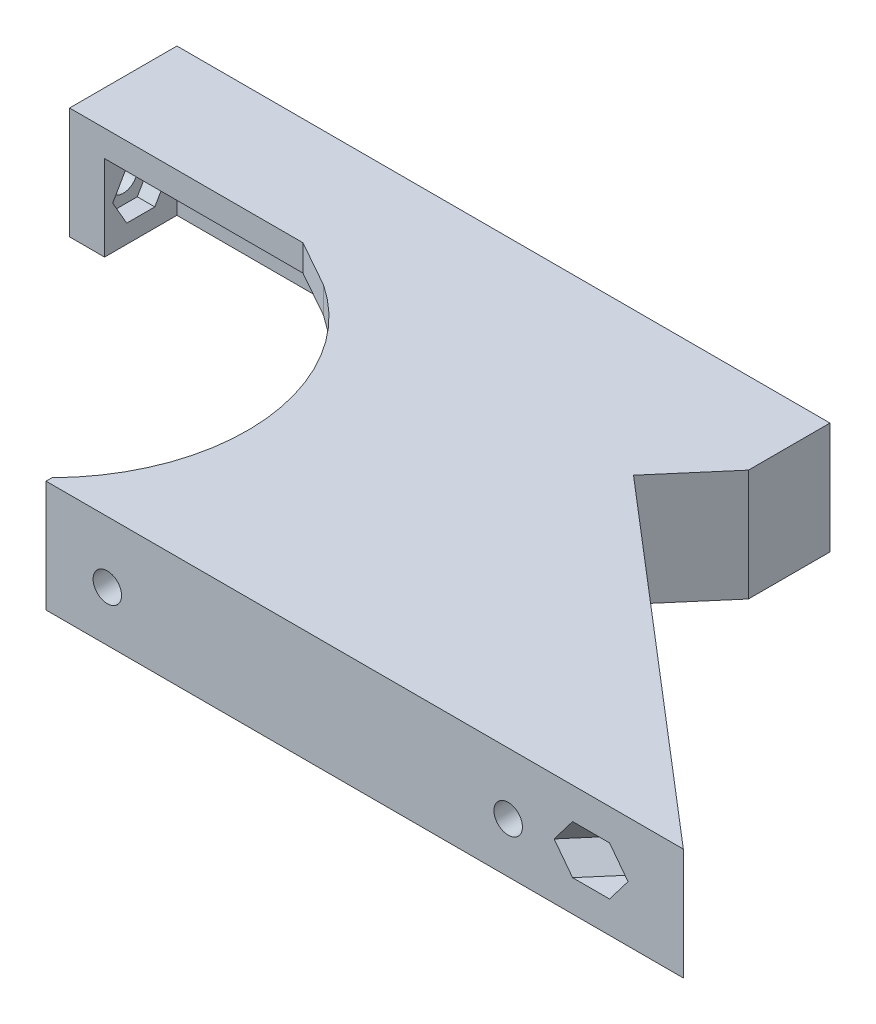
from build123d import *

# Parameters (mm, degrees)
SALIENTE_EXTRUIR1_DEPTH     = 12.75
CORTAR_EXTRUIR1_REACH       = 31.62
CROQUIS2_R                  = 1.625
CROQUIS3_R                  = 22.5
CORTAR_EXTRUIR2_DEPTH       = 13.75
SALIENTE_EXTRUIR2_DEPTH     = 3
SALIENTE_EXTRUIR3_DEPTH     = 9.75
CROQUIS6_R                  = 1.625
CORTAR_EXTRUIR3_DEPTH       = 10
CORTAR_EXTRUIR4_START       = -2
CORTAR_EXTRUIR4_DEPTH       = 10
CORTAR_EXTRUIR5_START       = -2
CORTAR_EXTRUIR5_DEPTH       = 10
CORTAR_EXTRUIR6_DEPTH       = 2
CORTAR_EXTRUIR7_REACH       = 37.25
CROQUIS10_R                 = 1.625
CORTAR_EXTRUIR8_DEPTH       = 2
CROQUIS12_W                 = 92.508691999
CROQUIS12_H                 = 24.255818813
CORTAR_EXTRUIR9_DEPTH       = 1
CORTAR_EXTRUIR9_DEPTH_BACK  = 36.25
SALIENTE_EXTRUIR4_DEPTH     = 12.75
CORTAR_EXTRUIR10_START      = -9.75
CORTAR_EXTRUIR10_DEPTH      = 9.75
CROQUIS16_W                 = 68.039065087
CROQUIS16_H                 = 12.75
CORTAR_EXTRUIR11_DEPTH      = 1
CROQUIS17_W                 = 40.657498706
CROQUIS17_H                 = 22.934549925
CORTAR_EXTRUIR12_DEPTH      = 1
CORTAR_EXTRUIR12_DEPTH_BACK = 13.75
SALIENTE_EXTRUIR5_REACH     = 14.75
CROQUIS18_W                 = 34.9120451
CROQUIS18_H                 = 3.951156815
CROQUIS20_R                 = 1.625
CORTAR_EXTRUIR14_DEPTH      = 10
CORTAR_EXTRUIR15_DEPTH      = 2
CROQUIS22_R                 = 1.625
CORTAR_EXTRUIR16_DEPTH      = 10
CORTAR_EXTRUIR17_DEPTH      = 2
SALIENTE_EXTRUIR6_DEPTH     = 12.75
CORTAR_EXTRUIR18_DEPTH      = 2
CROQUIS28_R                 = 1.625
SALIENTE_EXTRUIR7_DEPTH     = 1
CORTAR_EXTRUIR19_REACH      = 110.346
CROQUIS29_R                 = 1.625
CORTAR_EXTRUIR20_DEPTH      = 2
SALIENTE_EXTRUIR11_DEPTH    = 12.75
CROQUIS41_R                 = 1.625
CORTAR_EXTRUIR25_DEPTH      = 10
SALIENTE_EXTRUIR12_DEPTH    = 12.75
SALIENTE_EXTRUIR13_DEPTH    = 12.75
CORTAR_EXTRUIR26_DEPTH      = 13.75
SALIENTE_EXTRUIR14_START    = -9.15
SALIENTE_EXTRUIR14_DEPTH    = 5.55
SALIENTE_EXTRUIR15_REACH    = 14.75
CORTAR_EXTRUIR27_REACH      = 110.346
CROQUIS47_R                 = 1.625
CORTAR_EXTRUIR28_REACH      = 112.346
CORTAR_EXTRUIR28_START      = -2
CORTAR_EXTRUIR29_START      = -9.75
CORTAR_EXTRUIR29_DEPTH      = 9.75
CORTAR_EXTRUIR30_REACH      = 52.512
CROQUIS50_R                 = 1.625
CORTAR_EXTRUIR31_REACH      = 54.512
CORTAR_EXTRUIR31_START      = -2
CROQUIS19_W                 = 120.448667976
CROQUIS19_H                 = 32.886651308
CORTAR_EXTRUIR13_DEPTH      = 1
CORTAR_EXTRUIR13_DEPTH_BACK = 62.623336743


with BuildPart() as part:
    # Croquis1 → Saliente-Extruir1 (new body)
    with BuildSketch(Plane(origin=(0, 0, 0), x_dir=(1, 0, 0), z_dir=(0, 1, 0))):
        Polygon((0, 0), (72.78319995, 0), (38.224450787, 29.62043043), (35.621353918, 26.5833452), (60.803074847, 5), (0, 5), align=None)
    extrude(amount=SALIENTE_EXTRUIR1_DEPTH)

    # Croquis2 → Cortar-Extruir1 (cut, up to next)
    with BuildSketch(Plane.XY, mode=Mode.PRIVATE) as cortar_extruir1_sk1:
        with Locations((52.78319995, 5.75)):
            Circle(CROQUIS2_R)
    cortar_extruir1_tool1 = extrude(cortar_extruir1_sk1.sketch, amount=-CORTAR_EXTRUIR1_REACH, mode=Mode.PRIVATE) & part.part
    add(cortar_extruir1_tool1.solids().sort_by_distance((52.7832, 5.75, 0))[0], mode=Mode.SUBTRACT)
    # Croquis2 → Cortar-Extruir1 (cut, up to next)
    with BuildSketch(Plane.XY, mode=Mode.PRIVATE) as cortar_extruir1_sk2:
        with Locations((6.99999995, 5.75)):
            Circle(CROQUIS2_R)
    cortar_extruir1_tool2 = extrude(cortar_extruir1_sk2.sketch, amount=-CORTAR_EXTRUIR1_REACH, mode=Mode.PRIVATE) & part.part
    add(cortar_extruir1_tool2.solids().sort_by_distance((7, 5.75, 0))[0], mode=Mode.SUBTRACT)

    # Croquis3 → Cortar-Extruir2 (cut, through all)
    with BuildSketch(Plane(origin=(0, 12.75, 0), x_dir=(1, 0, 0), z_dir=(0, 1, 0))):
        with Locations((-16, 16.5)):
            Circle(CROQUIS3_R)
    extrude(amount=-CORTAR_EXTRUIR2_DEPTH, mode=Mode.SUBTRACT)

    # Croquis4 → Saliente-Extruir2 (add)
    with BuildSketch(Plane(origin=(0, 12.75, 0), x_dir=(1, 0, 0), z_dir=(0, 1, 0))):
        with BuildLine():
            Line((38.224450787, 29.62043043), (31.656319269, 35.25))
            Line((31.656319269, 35.25), (-3.562657036, 35.25))
            ThreePointArc((-3.562657036, 35.25), (5.936291456, 21.504909307), (3.339079606, 5))
            Line((3.339079606, 5), (60.803074847, 5))
            Line((60.803074847, 5), (35.621353918, 26.5833452))
            Line((35.621353918, 26.5833452), (38.224450787, 29.62043043))
        make_face()
    extrude(amount=-SALIENTE_EXTRUIR2_DEPTH)

    # Croquis5 → Saliente-Extruir3 (add)
    with BuildSketch(Plane.XZ.offset(-9.75)):
        with BuildLine():
            Line((-3.562657036, -35.25), (31.656319269, -35.25))
            Line((31.656319269, -35.25), (38.224450787, -29.62043043))
            Line((38.224450787, -29.62043043), (35.621353918, -26.5833452))
            Line((35.621353918, -26.5833452), (30.17667434, -31.25))
            Line((30.17667434, -31.25), (0.990806338, -31.25))
            ThreePointArc((0.990806338, -31.25), (-1.15062315, -33.404023402), (-3.562657036, -35.25))
        make_face()
    extrude(amount=SALIENTE_EXTRUIR3_DEPTH)

    # Croquis6 → Cortar-Extruir3 (cut)
    with BuildSketch(Plane(origin=(30.824200619, 0, -35.963211942), x_dir=(-0.759271307, 0, -0.650774217), z_dir=(0.650774217, 0, -0.759271307))):
        with Locations((-47.262195378, 6.375)):
            Circle(CROQUIS6_R)
        with Locations((-7.442195378, 6.375)):
            Circle(CROQUIS6_R)
    extrude(amount=-CORTAR_EXTRUIR3_DEPTH, mode=Mode.SUBTRACT)

    # Croquis7 → Cortar-Extruir4 (cut)
    with BuildSketch(Plane(origin=(28.22110375, 0, -32.926126712), x_dir=(0.759271307, 0, 0.650774217), z_dir=(-0.650774217, 0, 0.759271307)).offset(CORTAR_EXTRUIR4_START)):
        Polygon((48.864342375, 3.6), (50.466489372, 6.375), (48.864342375, 9.15), (45.660048381, 9.15), (44.057901384, 6.375), (45.660048381, 3.6), align=None)
    extrude(amount=CORTAR_EXTRUIR4_DEPTH, mode=Mode.SUBTRACT)

    # Croquis8 → Cortar-Extruir5 (cut)
    with BuildSketch(Plane(origin=(28.22110375, 0, -32.926126712), x_dir=(0.759271307, 0, 0.650774217), z_dir=(-0.650774217, 0, 0.759271307)).offset(CORTAR_EXTRUIR5_START)):
        Polygon((9.044342375, 3.6), (10.646489372, 6.375), (9.044342375, 9.15), (5.840048381, 9.15), (4.237901384, 6.375), (5.840048381, 3.6), align=None)
    extrude(amount=CORTAR_EXTRUIR5_DEPTH, mode=Mode.SUBTRACT)

    # Croquis9 → Cortar-Extruir6 (cut)
    with BuildSketch(Plane(origin=(0, 0, -5), x_dir=(-1, 0, 0), z_dir=(0, 0, -1))):
        Polygon((-5.397852953, 2.975), (-3.795705956, 5.75), (-5.397852953, 8.525), (-8.602146947, 8.525), (-10.204293944, 5.75), (-8.602146947, 2.975), align=None)
        Polygon((-51.181052953, 2.975), (-49.578905956, 5.75), (-51.181052953, 8.525), (-54.385346947, 8.525), (-55.987493944, 5.75), (-54.385346947, 2.975), align=None)
    extrude(amount=-CORTAR_EXTRUIR6_DEPTH, mode=Mode.SUBTRACT)

    # Croquis10 → Cortar-Extruir7 (cut, up to next)
    with BuildSketch(Plane(origin=(0, 0, -35.25), x_dir=(-1, 0, 0), z_dir=(0, 0, -1)), mode=Mode.PRIVATE) as cortar_extruir7_sk1:
        with Locations((-21.656319269, 6.375)):
            Circle(CROQUIS10_R)
    cortar_extruir7_tool1 = extrude(cortar_extruir7_sk1.sketch, amount=-CORTAR_EXTRUIR7_REACH, mode=Mode.PRIVATE) & part.part
    add(cortar_extruir7_tool1.solids().sort_by_distance((21.656319, 6.375, -35.25))[0], mode=Mode.SUBTRACT)

    # Croquis11 → Cortar-Extruir8 (cut)
    with BuildSketch(Plane.XY.offset(-31.25)):
        Polygon((23.258466266, 3.6), (24.860613263, 6.375), (23.258466266, 9.15), (20.054172272, 9.15), (18.452025275, 6.375), (20.054172272, 3.6), align=None)
    extrude(amount=-CORTAR_EXTRUIR8_DEPTH, mode=Mode.SUBTRACT)

    # Simetría1: part across plane


with BuildPart() as part_1:
    add(part.part)
    add(part.part.mirror(Plane.ZX))

    # Croquis12 → Cortar-Extruir9 (cut, two sides)
    with BuildSketch(Plane(origin=(0, 0, -35.25), x_dir=(-1, 0, 0), z_dir=(0, 0, -1))) as cortar_extruir9_sk:
        with Locations((-33.077560565, 12.127909407)):
            Rectangle(CROQUIS12_W, CROQUIS12_H)
    extrude(amount=CORTAR_EXTRUIR9_DEPTH, mode=Mode.SUBTRACT)
    extrude(cortar_extruir9_sk.sketch, amount=-CORTAR_EXTRUIR9_DEPTH_BACK, mode=Mode.SUBTRACT)

    # Croquis13 → Saliente-Extruir4 (add)
    with BuildSketch(Plane.XZ.offset(12.75)):
        Polygon((-35.562657036, -82.38260805), (-35.562657036, -38.25), (-8.913300435, -38.25), (-3.562657036, -35.25), (31.656319269, -35.25), (0.000162281, -62.38260805), align=None)
    extrude(amount=-SALIENTE_EXTRUIR4_DEPTH)

    # Croquis14 → Cortar-Extruir10 (cut)
    with BuildSketch(Plane(origin=(0, 0, 0), x_dir=(1, 0, 0), z_dir=(0, 1, 0)).offset(CORTAR_EXTRUIR10_START)):
        Polygon((30.17667434, 31.25), (0.990806338, 31.25), (-31.562657036, 38.25), (-31.562657036, 75.543902968), (-2.303881466, 59.089203295), align=None)
    extrude(amount=CORTAR_EXTRUIR10_DEPTH, mode=Mode.SUBTRACT)

    # Croquis16 → Cortar-Extruir11 (cut)
    with BuildSketch(Plane(origin=(30.824200619, 0, -35.963211942), x_dir=(-0.759271307, 0, -0.650774217), z_dir=(0.650774217, 0, -0.759271307))):
        with Locations((6.577337166, -6.375)):
            Rectangle(CROQUIS16_W, CROQUIS16_H)
    extrude(amount=-CORTAR_EXTRUIR11_DEPTH, mode=Mode.SUBTRACT)

    # Croquis17 → Cortar-Extruir12 (cut, two sides)
    with BuildSketch(Plane.XZ.offset(12.75)) as cortar_extruir12_sk:
        with Locations((-20.328587072, -73.090611706)):
            Rectangle(CROQUIS17_W, CROQUIS17_H)
    extrude(amount=CORTAR_EXTRUIR12_DEPTH, mode=Mode.SUBTRACT)
    extrude(cortar_extruir12_sk.sketch, amount=-CORTAR_EXTRUIR12_DEPTH_BACK, mode=Mode.SUBTRACT)

    # Croquis18 → Saliente-Extruir5 (add, up to next)
    with BuildSketch(Plane(origin=(0, 0, 0), x_dir=(1, 0, 0), z_dir=(0, 1, 0)), mode=Mode.PRIVATE) as saliente_extruir5_sk1:
        with Locations((-18.106634486, 59.647758336)):
            Rectangle(CROQUIS18_W, CROQUIS18_H)
    saliente_extruir5_tool1 = extrude(saliente_extruir5_sk1.sketch, amount=-SALIENTE_EXTRUIR5_REACH, mode=Mode.PRIVATE) - part_1.part
    add(saliente_extruir5_tool1.solids().sort_by_distance((-18.106634, 0, -59.647758))[0])

    # Croquis20 → Cortar-Extruir14 (cut)
    with BuildSketch(Plane(origin=(30.173426402, 0, -35.203940634), x_dir=(-0.759271307, 0, -0.650774217), z_dir=(0.650774217, 0, -0.759271307))):
        with Locations((25.596869709, -6.375)):
            Circle(CROQUIS20_R)
        with Locations((-7.442195378, -6.375)):
            Circle(CROQUIS20_R)
    extrude(amount=-CORTAR_EXTRUIR14_DEPTH, mode=Mode.SUBTRACT)

    # Croquis21 → Cortar-Extruir15 (cut)
    with BuildSketch(Plane(origin=(28.22110375, 0, -32.926126712), x_dir=(0.759271307, 0, 0.650774217), z_dir=(-0.650774217, 0, 0.759271307))):
        Polygon((-23.994722712, -9.15), (-22.392575715, -6.375), (-23.994722712, -3.6), (-27.199016706, -3.6), (-28.801163703, -6.375), (-27.199016706, -9.15), align=None)
    extrude(amount=-CORTAR_EXTRUIR15_DEPTH, mode=Mode.SUBTRACT)

    # Croquis22 → Cortar-Extruir16 (cut)
    with BuildSketch(Plane(origin=(0, 0, -61.623336743), x_dir=(-1, 0, 0), z_dir=(0, 0, -1))):
        with Locations((18.112657036, -6.375)):
            Circle(CROQUIS22_R)
    extrude(amount=-CORTAR_EXTRUIR16_DEPTH, mode=Mode.SUBTRACT)

    # Croquis23 → Cortar-Extruir17 (cut)
    with BuildSketch(Plane.XY.offset(-57.672179928)):
        Polygon((-16.510510039, -9.15), (-14.908363042, -6.375), (-16.510510039, -3.6), (-19.714804033, -3.6), (-21.31695103, -6.375), (-19.714804033, -9.15), align=None)
    extrude(amount=-CORTAR_EXTRUIR17_DEPTH, mode=Mode.SUBTRACT)

    # Croquis26 → Saliente-Extruir6 (add)
    with BuildSketch(Plane(origin=(0, 0, 0), x_dir=(1, 0, 0), z_dir=(0, 1, 0))):
        Polygon((60.803074847, 5), (-2.287792345, 59.07541325), (-2.938566562, 58.316141943), (60.15230063, 4.240728693), align=None)
    extrude(amount=-SALIENTE_EXTRUIR6_DEPTH)

    # Croquis27 → Cortar-Extruir18 (cut)
    with BuildSketch(Plane(origin=(27.570329533, 0, -32.166855405), x_dir=(0.759271307, 0, 0.650774217), z_dir=(-0.650774217, 0, 0.759271307))):
        Polygon((-22.421443229, -6.375), (-24.009156469, -3.625), (-27.184582949, -3.625), (-28.77229619, -6.375), (-27.184582949, -9.125), (-24.009156469, -9.125), align=None)
        Polygon((10.646489372, -6.375), (9.044342375, -3.6), (5.840048381, -3.6), (4.237901384, -6.375), (5.840048381, -9.15), (9.044342375, -9.15), align=None)
    extrude(amount=-CORTAR_EXTRUIR18_DEPTH, mode=Mode.SUBTRACT)

    # Croquis28 → Saliente-Extruir7 (add)
    with BuildSketch(Plane(origin=(29.522652185, 0, -34.444669327), x_dir=(0.759271307, 0, 0.650774217), z_dir=(-0.650774217, 0, 0.759271307))):
        Polygon((-24.009156469, -3.625), (-27.184582949, -3.625), (-28.77229619, -6.375), (-27.184582949, -9.125), (-24.009156469, -9.125), (-22.421443229, -6.375), align=None)
        with Locations((-25.596869709, -6.375)):
            Circle(CROQUIS28_R, mode=Mode.SUBTRACT)
        Polygon((10.646489372, -6.375), (9.044342375, -3.6), (5.840048381, -3.6), (4.237901384, -6.375), (5.840048381, -9.15), (9.044342375, -9.15), align=None)
        with Locations((7.442195378, -6.375)):
            Circle(CROQUIS28_R, mode=Mode.SUBTRACT)
    extrude(amount=SALIENTE_EXTRUIR7_DEPTH)

    # Croquis29 → Cortar-Extruir19 (cut, up to next)
    with BuildSketch(Plane.ZY.offset(35.562657036), mode=Mode.PRIVATE) as cortar_extruir19_sk1:
        with Locations((-51.623336743, -6.375)):
            Circle(CROQUIS29_R)
    cortar_extruir19_tool1 = extrude(cortar_extruir19_sk1.sketch, amount=-CORTAR_EXTRUIR19_REACH, mode=Mode.PRIVATE) & part_1.part
    add(cortar_extruir19_tool1.solids().sort_by_distance((-35.562657, -6.375, -51.623337))[0], mode=Mode.SUBTRACT)

    # Croquis30 → Cortar-Extruir20 (cut)
    with BuildSketch(Plane(origin=(-31.562657036, 0, 0), x_dir=(0, 0, -1), z_dir=(1, 0, 0))):
        Polygon((53.22548374, -9.15), (54.827630737, -6.375), (53.22548374, -3.6), (50.021189746, -3.6), (48.419042749, -6.375), (50.021189746, -9.15), align=None)
    extrude(amount=-CORTAR_EXTRUIR20_DEPTH, mode=Mode.SUBTRACT)

    # Croquis40 → Saliente-Extruir11 (add)
    with BuildSketch(Plane.XZ.offset(12.75)):
        Polygon((51.009497963, -17.345267417), (-0.650611936, -61.623336743), (0.886019316, -61.623336743), (51.66027218, -18.104538724), align=None)
    extrude(amount=-SALIENTE_EXTRUIR11_DEPTH)

    # Croquis41 → Cortar-Extruir25 (cut)
    with BuildSketch(Plane(origin=(30.824200619, 0, -35.963211942), x_dir=(-0.759271307, 0, -0.650774217), z_dir=(0.650774217, 0, -0.759271307))):
        with Locations((-7.442195378, -6.375)):
            Circle(CROQUIS41_R)
        with Locations((25.596869709, -6.375)):
            Circle(CROQUIS41_R)
    extrude(amount=-CORTAR_EXTRUIR25_DEPTH, mode=Mode.SUBTRACT)

    # Croquis42 → Saliente-Extruir12 (add)
    with BuildSketch(Plane.XZ.offset(12.75)):
        Polygon((32.95941988, -34.133107696), (39.018127843, -41.201923567), (24.71209089, -41.201923567), align=None)
    extrude(amount=-SALIENTE_EXTRUIR12_DEPTH)

    # Croquis43 → Saliente-Extruir13 (add)
    with BuildSketch(Plane.XZ.offset(12.75)):
        Polygon((39.018127843, -41.201923567), (39.018127843, -50.511923567), (13.849927511, -50.511923567), (24.71209089, -41.201923567), align=None)
    extrude(amount=-SALIENTE_EXTRUIR13_DEPTH)

    # Croquis44 → Cortar-Extruir26 (cut, through all)
    with BuildSketch(Plane.XZ.offset(12.75)):
        Polygon((13.849927511, -50.511923567), (-35.562657036, -50.511923567), (-35.562657036, -61.623336743), (0.886019316, -61.623336743), align=None)
    extrude(amount=-CORTAR_EXTRUIR26_DEPTH, mode=Mode.SUBTRACT)

    # Croquis45 → Saliente-Extruir14 (add)
    with BuildSketch(Plane(origin=(0, 0, 0), x_dir=(1, 0, 0), z_dir=(0, 1, 0)).offset(SALIENTE_EXTRUIR14_START)):
        Polygon((6.166771253, 50.511923567), (21.724093533, 50.511923567), (21.724093533, 37.177685684), align=None)
    extrude(amount=SALIENTE_EXTRUIR14_DEPTH)

    # Croquis46 → Saliente-Extruir15 (add, up to next)
    with BuildSketch(Plane(origin=(0, 0, 0), x_dir=(1, 0, 0), z_dir=(0, 1, 0)), mode=Mode.PRIVATE) as saliente_extruir15_sk1:
        Polygon((-35.562657036, 50.511923567), (-31.562657036, 50.511923567), (10.83365133, 50.511923567), (10.83365133, 46.511923567), (-31.562657036, 46.511923567), (-31.562657036, 38.25), (-35.562657036, 38.25), align=None)
    saliente_extruir15_tool1 = extrude(saliente_extruir15_sk1.sketch, amount=-SALIENTE_EXTRUIR15_REACH, mode=Mode.PRIVATE) - part_1.part
    add(saliente_extruir15_tool1.solids().sort_by_distance((-15.568733, 0, -47.585191))[0])

    # Croquis47 → Cortar-Extruir27 (cut, up to next)
    with BuildSketch(Plane.ZY.offset(35.562657036), mode=Mode.PRIVATE) as cortar_extruir27_sk1:
        with Locations((-42.380961783, -4.875)):
            Circle(CROQUIS47_R)
    cortar_extruir27_tool1 = extrude(cortar_extruir27_sk1.sketch, amount=-CORTAR_EXTRUIR27_REACH, mode=Mode.PRIVATE) & part_1.part
    add(cortar_extruir27_tool1.solids().sort_by_distance((-35.562657, -4.875, -42.380962))[0], mode=Mode.SUBTRACT)

    # Croquis48 → Cortar-Extruir28 (cut, up to next)
    with BuildSketch(Plane.ZY.offset(35.562657036).offset(CORTAR_EXTRUIR28_START), mode=Mode.PRIVATE) as cortar_extruir28_sk1:
        Polygon((-40.778814786, -7.65), (-39.176667789, -4.875), (-40.778814786, -2.1), (-43.98310878, -2.1), (-45.585255777, -4.875), (-43.98310878, -7.65), align=None)
    cortar_extruir28_tool1 = extrude(cortar_extruir28_sk1.sketch, amount=-CORTAR_EXTRUIR28_REACH, mode=Mode.PRIVATE) & part_1.part
    add(cortar_extruir28_tool1.solids().sort_by_distance((-33.562657, -4.875, -42.380962))[0], mode=Mode.SUBTRACT)

    # Croquis49 → Cortar-Extruir29 (cut)
    with BuildSketch(Plane(origin=(0, 0, 0), x_dir=(1, 0, 0), z_dir=(0, 1, 0)).offset(CORTAR_EXTRUIR29_START)):
        Polygon((26.668463565, 32.939848028), (35.018127843, 42.681568496), (35.018127843, 46.511923567), (10.83365133, 46.511923567), align=None)
    extrude(amount=CORTAR_EXTRUIR29_DEPTH, mode=Mode.SUBTRACT)

    # Croquis50 → Cortar-Extruir30 (cut, up to next)
    with BuildSketch(Plane(origin=(0, 0, -50.511923567), x_dir=(-1, 0, 0), z_dir=(0, 0, -1)), mode=Mode.PRIVATE) as cortar_extruir30_sk1:
        with Locations((25.562657036, -6.75)):
            Circle(CROQUIS50_R)
    cortar_extruir30_tool1 = extrude(cortar_extruir30_sk1.sketch, amount=-CORTAR_EXTRUIR30_REACH, mode=Mode.PRIVATE) & part_1.part
    add(cortar_extruir30_tool1.solids().sort_by_distance((-25.562657, -6.75, -50.511924))[0], mode=Mode.SUBTRACT)
    # Croquis50 → Cortar-Extruir30 (cut, up to next)
    with BuildSketch(Plane(origin=(0, 0, -50.511923567), x_dir=(-1, 0, 0), z_dir=(0, 0, -1)), mode=Mode.PRIVATE) as cortar_extruir30_sk2:
        with Locations((-24.437342964, -6.75)):
            Circle(CROQUIS50_R)
    cortar_extruir30_tool2 = extrude(cortar_extruir30_sk2.sketch, amount=-CORTAR_EXTRUIR30_REACH, mode=Mode.PRIVATE) & part_1.part
    add(cortar_extruir30_tool2.solids().sort_by_distance((24.437343, -6.75, -50.511924))[0], mode=Mode.SUBTRACT)

    # Croquis51 → Cortar-Extruir31 (cut, up to next)
    with BuildSketch(Plane(origin=(0, 0, -50.511923567), x_dir=(-1, 0, 0), z_dir=(0, 0, -1)).offset(CORTAR_EXTRUIR31_START), mode=Mode.PRIVATE) as cortar_extruir31_sk1:
        Polygon((-22.835195967, -9.525), (-21.23304897, -6.75), (-22.835195967, -3.975), (-26.039489961, -3.975), (-27.641636958, -6.75), (-26.039489961, -9.525), align=None)
    cortar_extruir31_tool1 = extrude(cortar_extruir31_sk1.sketch, amount=-CORTAR_EXTRUIR31_REACH, mode=Mode.PRIVATE) & part_1.part
    add(cortar_extruir31_tool1.solids().sort_by_distance((24.437343, -6.75, -48.511924))[0], mode=Mode.SUBTRACT)
    # Croquis51 → Cortar-Extruir31 (cut, up to next)
    with BuildSketch(Plane(origin=(0, 0, -50.511923567), x_dir=(-1, 0, 0), z_dir=(0, 0, -1)).offset(CORTAR_EXTRUIR31_START), mode=Mode.PRIVATE) as cortar_extruir31_sk2:
        Polygon((27.164804033, -9.525), (28.76695103, -6.75), (27.164804033, -3.975), (23.960510039, -3.975), (22.358363042, -6.75), (23.960510039, -9.525), align=None)
    cortar_extruir31_tool2 = extrude(cortar_extruir31_sk2.sketch, amount=-CORTAR_EXTRUIR31_REACH, mode=Mode.PRIVATE) & part_1.part
    add(cortar_extruir31_tool2.solids().sort_by_distance((-25.562657, -6.75, -48.511924))[0], mode=Mode.SUBTRACT)

    # Simetría2: part across face


with BuildPart() as part_2:
    add(part_1.part)
    add(part_1.part.mirror(Plane(origin=(19.502677982, -12.75, -25.93599085), x_dir=(0, 0, 1), z_dir=(0, -1, 0))))

    # Croquis19 → Cortar-Extruir13 (cut, two sides)
    with BuildSketch(Plane(origin=(0, 0, -61.623336743), x_dir=(-1, 0, 0), z_dir=(0, 0, -1))) as cortar_extruir13_sk:
        with Locations((-18.558865962, 3.693325654)):
            Rectangle(CROQUIS19_W, CROQUIS19_H)
    extrude(amount=CORTAR_EXTRUIR13_DEPTH, mode=Mode.SUBTRACT)
    extrude(cortar_extruir13_sk.sketch, amount=-CORTAR_EXTRUIR13_DEPTH_BACK, mode=Mode.SUBTRACT)


solid = part_2.part
